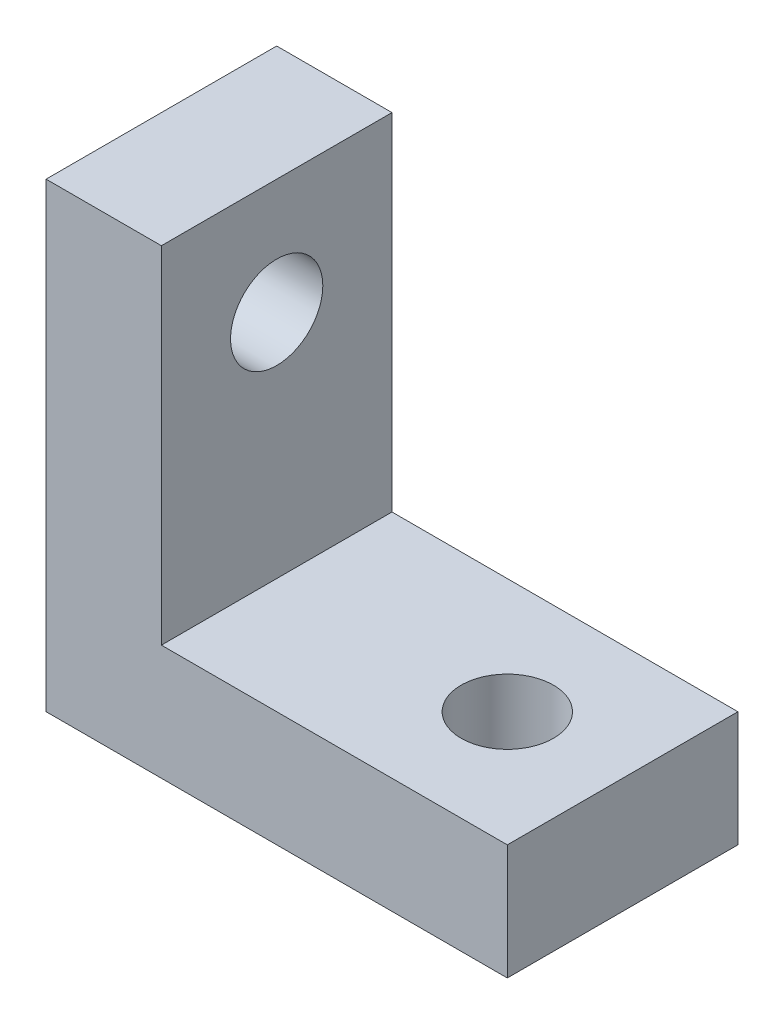
from build123d import *

# Parameters (mm, degrees)
SKETCH1_W           = 5
SKETCH1_H           = 15
SKETCH1_H_2         = 5
SKETCH1_W_2         = 15
BOSS_EXTRUDE2_DEPTH = 10
SKETCH3_R           = 2
CUT_EXTRUDE1_DEPTH  = 6
SKETCH4_R           = 2
CUT_EXTRUDE2_DEPTH  = 6


with BuildPart() as part:
    # Sketch1 → Boss-Extrude2 (new body)
    with BuildSketch(Plane.XY):
        with Locations((-7.340572317, 12.5)):
            Rectangle(SKETCH1_W, SKETCH1_H)
        with Locations((-7.340572317, 2.5)):
            Rectangle(SKETCH1_W, SKETCH1_H_2)
        with Locations((2.659427683, 2.5)):
            Rectangle(SKETCH1_W_2, SKETCH1_H_2)
    extrude(amount=BOSS_EXTRUDE2_DEPTH)

    # Sketch3 → Cut-Extrude1 (cut, through all)
    with BuildSketch(Plane(origin=(0, 5, 0), x_dir=(1, 0, 0), z_dir=(0, 1, 0))):
        with Locations((5.159427683, -5)):
            Circle(SKETCH3_R)
    extrude(amount=-CUT_EXTRUDE1_DEPTH, mode=Mode.SUBTRACT)

    # Sketch4 → Cut-Extrude2 (cut, through all)
    with BuildSketch(Plane(origin=(-4.840572317, 0, 0), x_dir=(0, 0, -1), z_dir=(1, 0, 0))):
        with Locations((-5, 15)):
            Circle(SKETCH4_R)
    extrude(amount=-CUT_EXTRUDE2_DEPTH, mode=Mode.SUBTRACT)


solid = part.part
